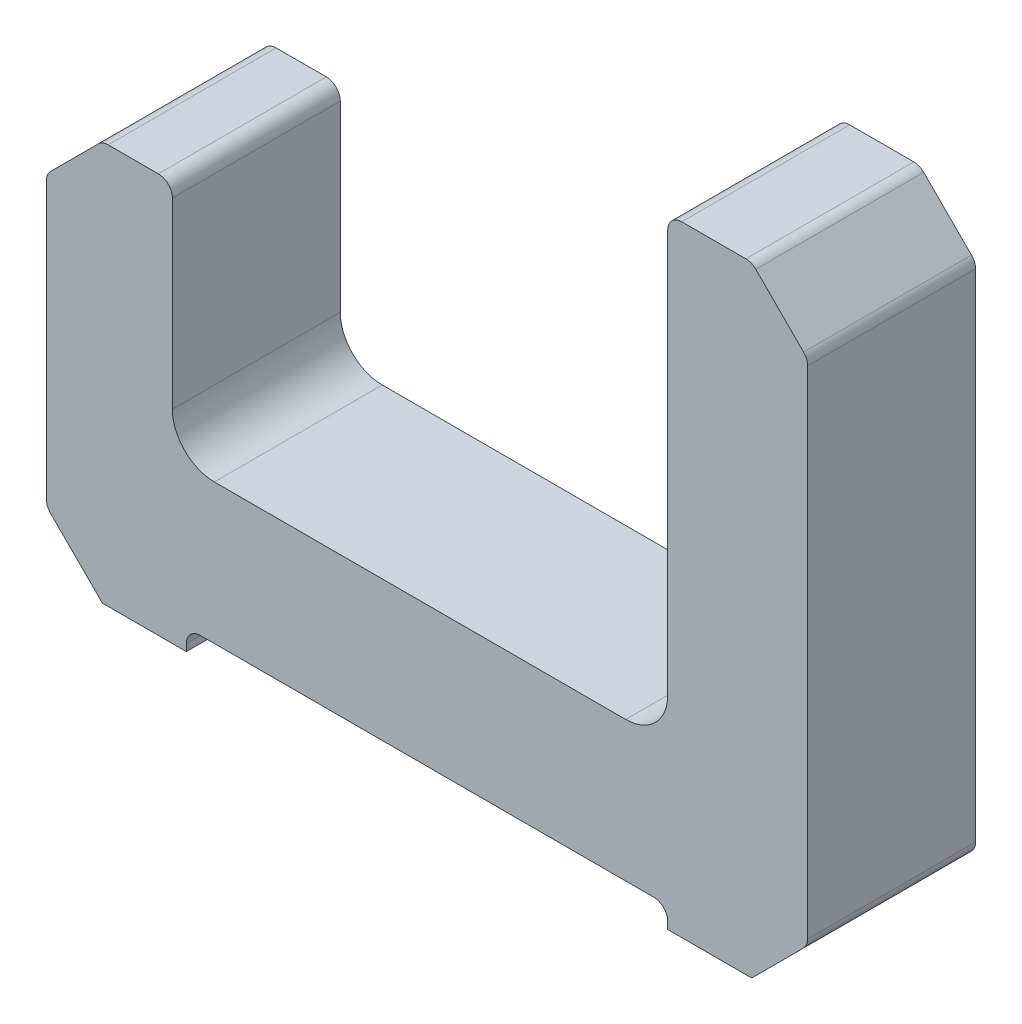
from build123d import *

# Parameters (mm, degrees)
BOSS_EXTRUDE1_DEPTH      = 30
BOSS_EXTRUDE1_DEPTH_BACK = 30
CHAMFER1_SIZE            = 20
FILLET1_R                = 15
FILLET2_R                = 5


with BuildPart() as part:
    # Sketch2 → Boss-Extrude1 (new, two sides: drawn at the far end of the back side and taken through both)
    with BuildSketch(Plane.XY.offset(-BOSS_EXTRUDE1_DEPTH_BACK)):
        Polygon((-133.5, 85.338455572), (-88.5, 85.338455572), (-88.5, 0), (88.5, 0), (88.5, 164), (138.5, 164), (138.5, -57.5), (88.5, -57.5), (88.5, -50), (-83.5, -50), (-83.5, -57.5), (-133.5, -57.5), align=None)
    extrude(amount=BOSS_EXTRUDE1_DEPTH + BOSS_EXTRUDE1_DEPTH_BACK)

    # Chamfer1
    chamfer1_edges = [part.edges().sort_by_distance(p)[0] for p in [
        (-133.5, -57.5, 0),
        (138.5, -57.5, 0),
        (138.5, 164, 0),
        (-133.5, 85.338455572, 0),
    ]]
    chamfer(chamfer1_edges, length=CHAMFER1_SIZE)

    # Fillet1
    fillet1_edges = [part.edges().sort_by_distance(p)[0] for p in [
        (88.5, 0, 0),
        (-88.5, 0, 0),
    ]]
    fillet(fillet1_edges, radius=FILLET1_R)

    # Fillet2
    fillet2_edges = [part.edges().sort_by_distance(p)[0] for p in [
        (138.5, -37.5, 0),
        (88.5, -50, 0),
        (-83.5, -50, 0),
        (-133.5, -37.5, 0),
        (-133.5, 65.338455572, 0),
        (-113.5, 85.338455572, 0),
        (-88.5, 85.338455572, 0),
        (138.5, 144, 0),
        (118.5, 164, 0),
        (88.5, 164, 0),
    ]]
    fillet(fillet2_edges, radius=FILLET2_R)


solid = part.part
